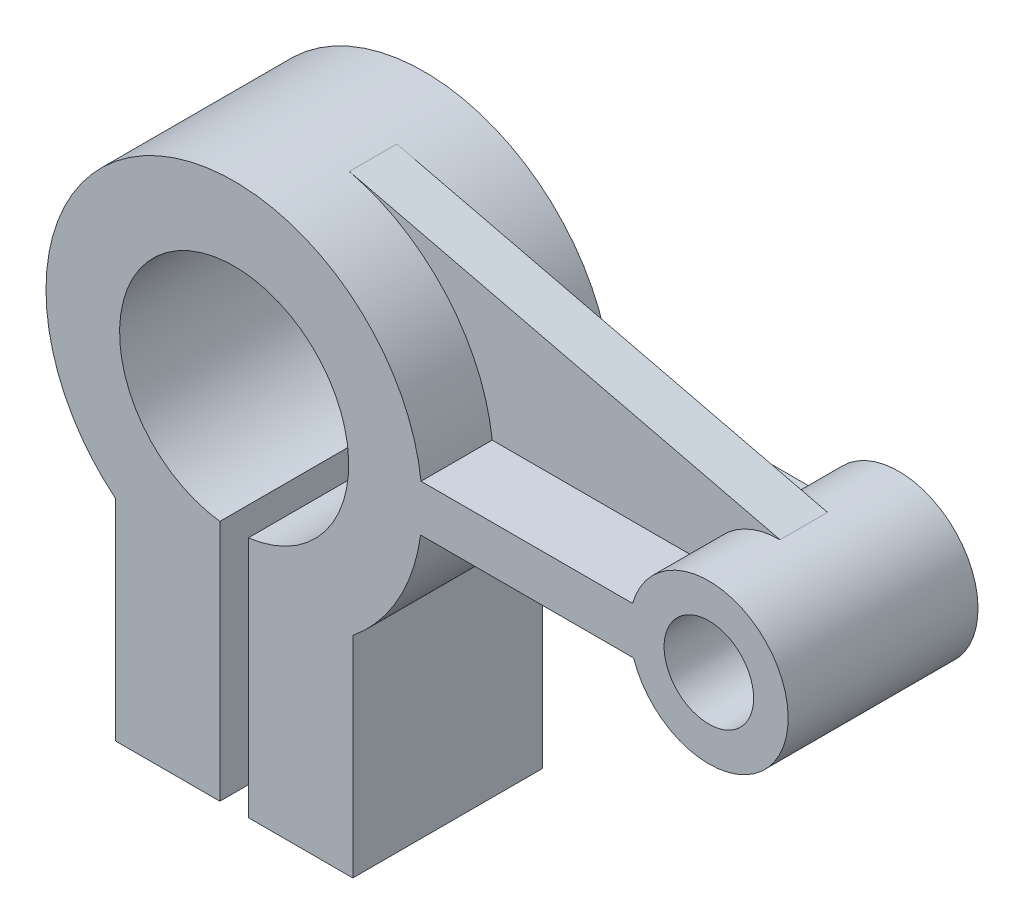
from build123d import *

# Parameters (mm, degrees)
BOSS_EXTRUDE1_DEPTH = 20
SKETCH2_3_R         = 9.427573189
CUT_EXTRUDE1_DEPTH  = 20
RIB14_REACH         = 148.086
SKETCH4_WALL_W      = 387.490512318
SKETCH4_WALL_H      = 10


with BuildPart() as part:
    # Sketch2 → Boss-Extrude1 (new, symmetric)
    with BuildSketch(Plane.XY):
        with BuildLine():
            Line((-47.815474815, 9.850065555), (-3.248646384, 9.850065555))
            ThreePointArc((-3.248646384, 9.850065555), (29.513615172, 5.671147892), (-3.023551525, 0))
            Line((-3.023551525, 0), (-47.906799475, 0))
            ThreePointArc((-47.906799475, 0), (-52.615248836, -14.092543666), (-62.182699169, -25.460620745))
            Line((-62.182699169, -25.460620745), (-62.182699169, -69.710398251))
            Line((-62.182699169, -69.710398251), (-84.182699169, -69.710398251))
            Line((-84.182699169, -69.710398251), (-84.182699169, -18.657805359))
            ThreePointArc((-84.182699169, -18.657805359), (-87.182699169, 29.424189114), (-90.182699169, -18.657805359))
            Line((-90.182699169, -18.657805359), (-90.182699169, -69.710398251))
            Line((-90.182699169, -69.710398251), (-112.182699169, -69.710398251))
            Line((-112.182699169, -69.710398251), (-112.182699169, -25.460620745))
            ThreePointArc((-112.182699169, -25.460620745), (-106.243534032, 40.035259864), (-47.815474815, 9.850065555))
        make_face()
    extrude(amount=BOSS_EXTRUDE1_DEPTH, both=True)

    # Sketch2_3 → Cut-Extrude1 (cut, symmetric)
    with BuildSketch(Plane.XY):
        with Locations((12.817300831, 5.289601749)):
            Circle(SKETCH2_3_R)
    extrude(amount=CUT_EXTRUDE1_DEPTH, both=True, mode=Mode.SUBTRACT)

    # Sketch4 wall → Rib14 (add, up to next)
    with BuildSketch(Plane(origin=(-32.547275207, 32.905370949, 0), x_dir=(0.972252919165, -0.233932172167, 0), z_dir=(0.233932172167, 0.972252919165, 0)), mode=Mode.PRIVATE) as rib14_sk1:
        Rectangle(SKETCH4_WALL_W, SKETCH4_WALL_H)
    rib14_tool1 = extrude(rib14_sk1.sketch, amount=-RIB14_REACH, mode=Mode.PRIVATE) - part.part
    add(rib14_tool1.solids().sort_by_distance((-32.547275207, 32.905370949, 0))[0])


solid = part.part
